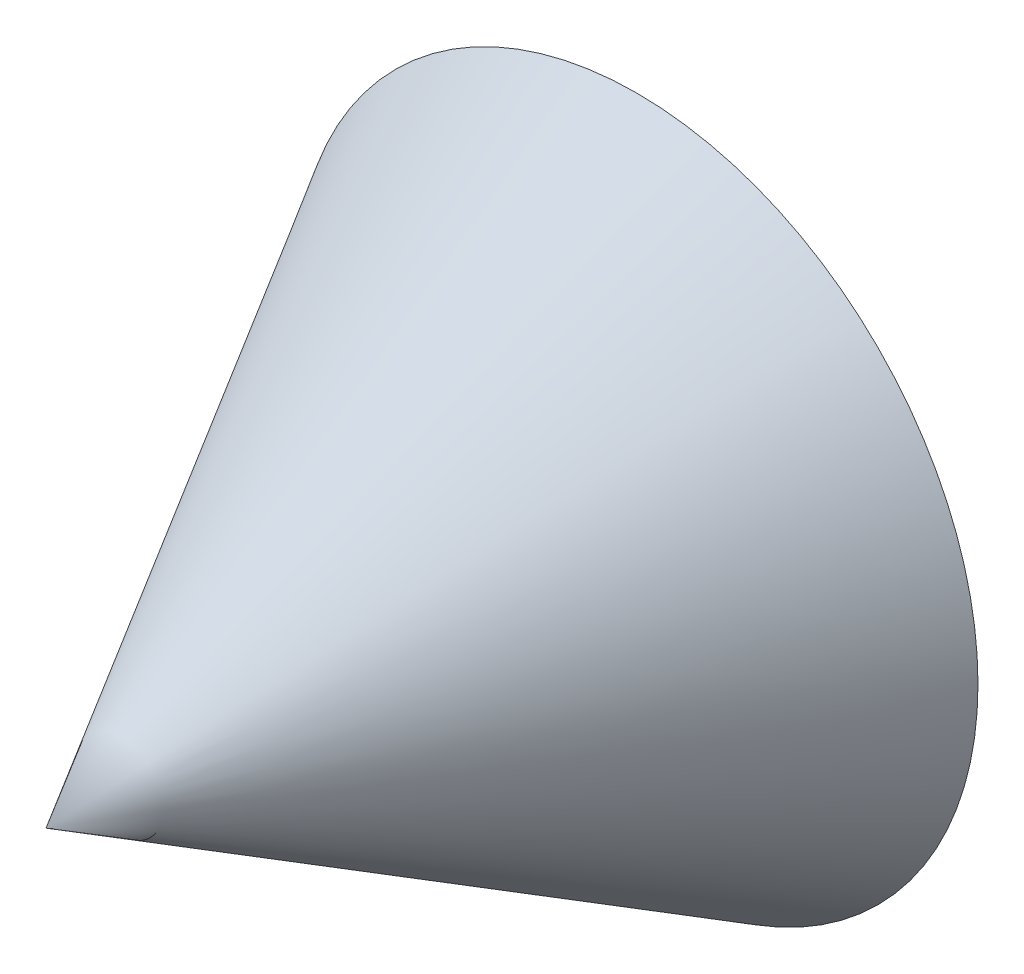
from build123d import *


with BuildPart() as part:
    # Sketch1 → Revolve1 (revolve)
    with BuildSketch(Plane(origin=(0, 0, 0), x_dir=(1, 0, 0), z_dir=(0, 1, 0))):
        Polygon((0, 0), (0, 200), (115.470053838, 200), align=None)
    revolve(axis=Axis((0, 0, 0), (0, 0, -1)))


solid = part.part
